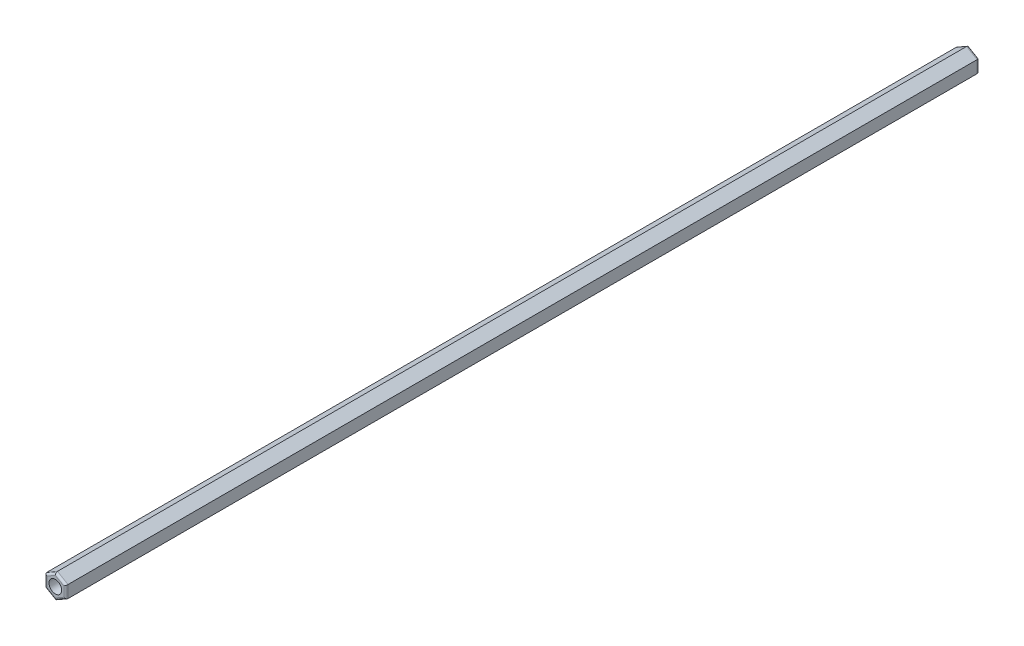
from build123d import *

# Parameters (mm, degrees)
RESSALTO_EXTRUS_O1_DEPTH = 216
FILETE1_R                = 0.5
ESBO_O2_R                = 1.5
CORTE_EXTRUS_O1_DEPTH    = 217


with BuildPart() as part:
    # Esboço1 → Ressalto-extrusão1 (new body)
    with BuildSketch(Plane(origin=(0, 0, 0), x_dir=(-1, 0, 0), z_dir=(0, 0, -1))):
        Polygon((67.502122675, -1.443375673), (70.002122675, -2.886751346), (72.502122675, -1.443375673), (72.502122675, 1.443375673), (70.002122675, 2.886751346), (67.502122675, 1.443375673), align=None)
    extrude(amount=-RESSALTO_EXTRUS_O1_DEPTH)

    # Filete1
    filete1_edges = [part.edges().sort_by_distance(p)[0] for p in [
        (-71.252122675, -2.165063509, 216),
        (-72.502122675, 0, 216),
        (-71.252122675, 2.165063509, 216),
        (-68.752122675, 2.165063509, 216),
        (-67.502122675, 0, 216),
        (-68.752122675, 2.165063509, 0),
        (-71.252122675, 2.165063509, 0),
        (-72.502122675, 0, 0),
        (-71.252122675, -2.165063509, 0),
        (-68.752122675, -2.165063509, 0),
        (-67.502122675, 0, 0),
        (-68.752122675, -2.165063509, 216),
    ]]
    fillet(filete1_edges, radius=FILETE1_R)

    # Esboço2 → Corte-extrusão1 (cut, through all)
    with BuildSketch(Plane.XY.offset(216)):
        with Locations((-70.002122675, 0)):
            Circle(ESBO_O2_R)
    extrude(amount=-CORTE_EXTRUS_O1_DEPTH, mode=Mode.SUBTRACT)


solid = part.part
